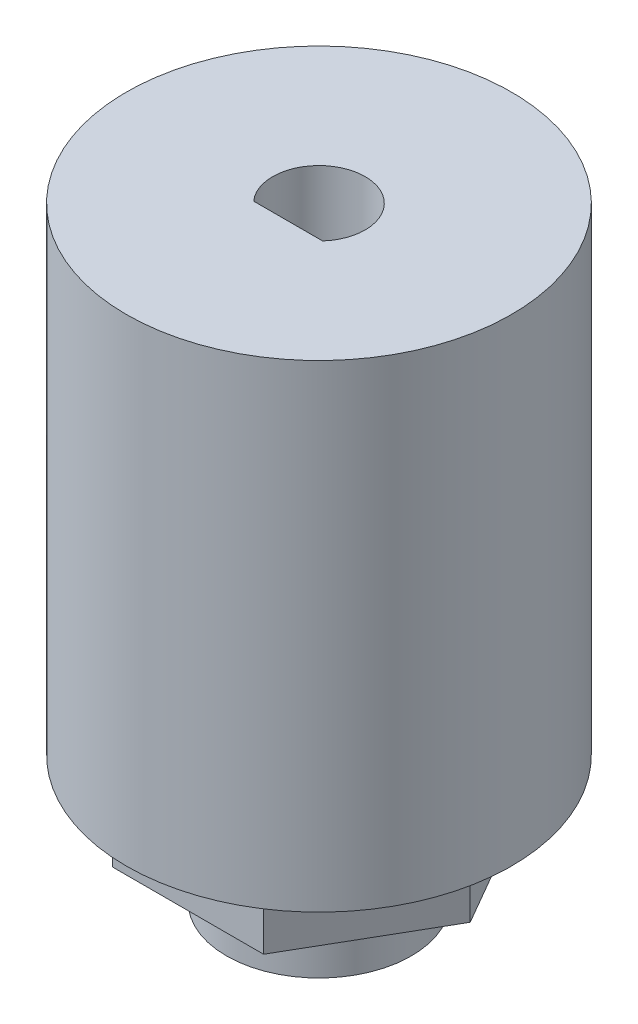
from build123d import *

# Parameters (mm, degrees)
SKETCH1_R           = 6
BOSS_EXTRUDE1_DEPTH = 3.8
BOSS_EXTRUDE2_DEPTH = 4.5
SKETCH3_R           = 12.5
BOSS_EXTRUDE3_DEPTH = 4
SKETCH4_R           = 12.5
BOSS_EXTRUDE4_DEPTH = 27
CUT_EXTRUDE1_DEPTH  = 40.3
SKETCH6_R           = 3.6
CUT_EXTRUDE2_DEPTH  = 6


with BuildPart() as part:
    # Sketch1 → Boss-Extrude1 (new body)
    with BuildSketch(Plane(origin=(0, 0, 0), x_dir=(1, 0, 0), z_dir=(0, 1, 0))):
        Circle(SKETCH1_R)
    extrude(amount=BOSS_EXTRUDE1_DEPTH)

    # Sketch2 → Boss-Extrude2 (add)
    with BuildSketch(Plane(origin=(0, 3.8, 0), x_dir=(1, 0, 0), z_dir=(0, 1, 0))):
        Polygon((9.814954576, 0), (4.907477288, 8.5), (-4.907477288, 8.5), (-9.814954576, 0), (-4.907477288, -8.5), (4.907477288, -8.5), align=None)
    extrude(amount=BOSS_EXTRUDE2_DEPTH)

    # Sketch3 → Boss-Extrude3 (add)
    with BuildSketch(Plane(origin=(0, 8.3, 0), x_dir=(1, 0, 0), z_dir=(0, 1, 0))):
        Circle(SKETCH3_R)
    extrude(amount=BOSS_EXTRUDE3_DEPTH)

    # Sketch4 → Boss-Extrude4 (add)
    with BuildSketch(Plane(origin=(0, 12.3, 0), x_dir=(1, 0, 0), z_dir=(0, 1, 0))):
        Circle(SKETCH4_R)
    extrude(amount=BOSS_EXTRUDE4_DEPTH)

    # Sketch5 → Cut-Extrude1 (cut, through all)
    with BuildSketch(Plane(origin=(0, 39.3, 0), x_dir=(1, 0, 0), z_dir=(0, 1, 0))):
        with BuildLine():
            ThreePointArc((3, 0), (-1.070466269, 2.802517077), (-2.236067977, -2))
            Line((-2.236067977, -2), (2.236067977, -2))
            ThreePointArc((2.236067977, -2), (2.802517077, -1.070466269), (3, 0))
        make_face()
    extrude(amount=-CUT_EXTRUDE1_DEPTH, mode=Mode.SUBTRACT)

    # Sketch6 → Cut-Extrude2 (cut)
    with BuildSketch(Plane.XZ):
        Circle(SKETCH6_R)
    extrude(amount=-CUT_EXTRUDE2_DEPTH, mode=Mode.SUBTRACT)


solid = part.part
